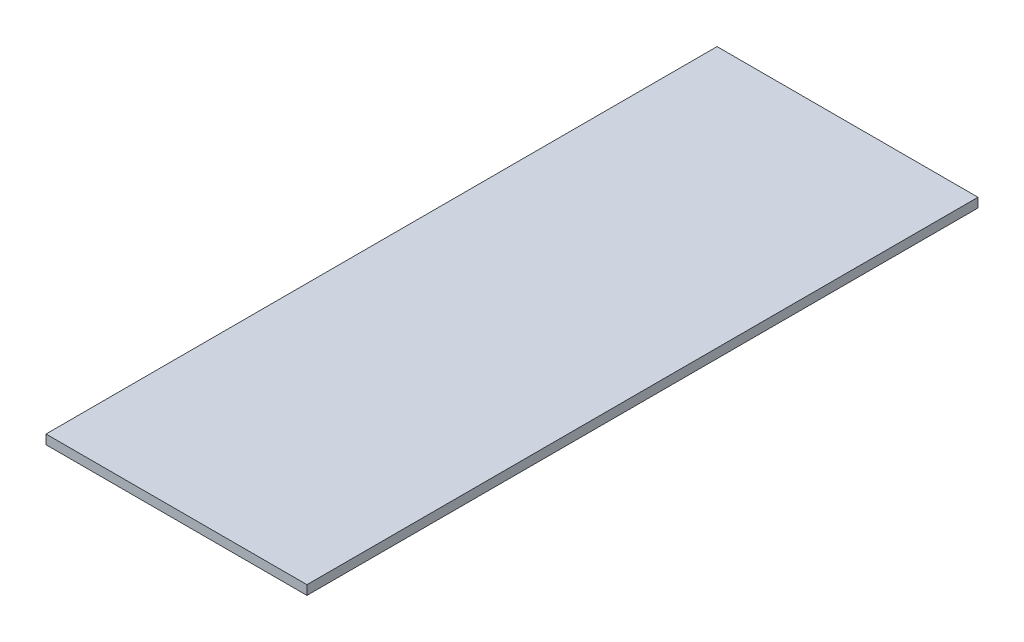
from build123d import *

# Parameters (mm, degrees)
SKETCH1_W           = 88.9
SKETCH1_H           = 228.6
BOSS_EXTRUDE1_DEPTH = 3.175


with BuildPart() as part:
    # Sketch1 → Boss-Extrude1 (new body)
    with BuildSketch(Plane(origin=(0, 0, 0), x_dir=(1, 0, 0), z_dir=(0, 1, 0))):
        with Locations((7.512751876, -84.194405918)):
            Rectangle(SKETCH1_W, SKETCH1_H)
    extrude(amount=BOSS_EXTRUDE1_DEPTH)


solid = part.part
